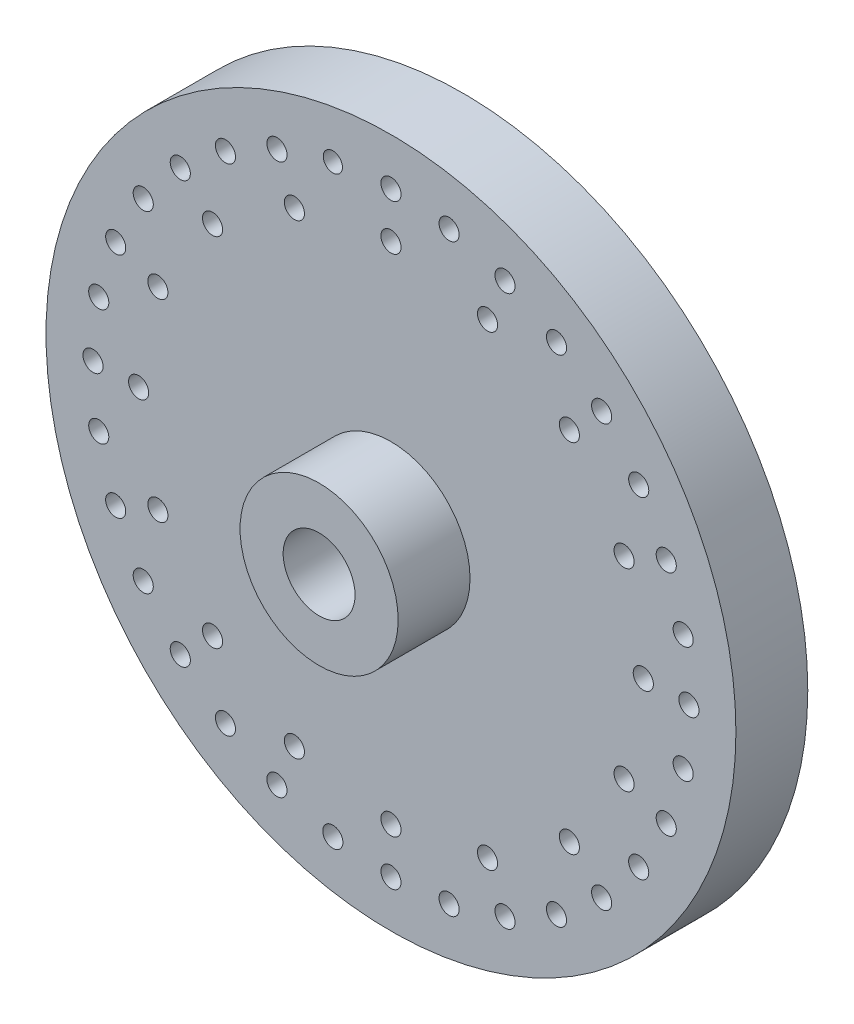
from build123d import *

# Parameters (mm, degrees)
SKETCH1_R          = 24
EXTRUDE1_DEPTH     = 5
SKETCH2_R          = 5.5
EXTRUDE2_DEPTH     = 5
SKETCH3_R          = 2.5
CUT_EXTRUDE1_DEPTH = 11
SKETCH4_R          = 0.7
SKETCH4_R_2        = 0.66767911
CUT_EXTRUDE2_DEPTH = 6


with BuildPart() as part:
    # Sketch1 → Extrude1 (new body)
    with BuildSketch(Plane.XY):
        Circle(SKETCH1_R)
    extrude(amount=EXTRUDE1_DEPTH)

    # Sketch2 → Extrude2 (add)
    with BuildSketch(Plane.XY.offset(5)):
        Circle(SKETCH2_R)
    extrude(amount=EXTRUDE2_DEPTH)

    # Sketch3 → Cut-Extrude1 (cut, through all)
    with BuildSketch(Plane.XY.offset(10)):
        Circle(SKETCH3_R)
    extrude(amount=-CUT_EXTRUDE1_DEPTH, mode=Mode.SUBTRACT)

    # Sketch4 → Cut-Extrude2 (cut, through all)
    with BuildSketch(Plane.XY.offset(5)):
        with Locations((0, 20.73)):
            Circle(SKETCH4_R)
        with Locations((0, -20.73)):
            Circle(SKETCH4_R)
        with Locations((20.73, 0)):
            Circle(SKETCH4_R)
        with Locations((-20.73, 0)):
            Circle(SKETCH4_R)
        with Locations((-14.658, 14.658)):
            Circle(SKETCH4_R)
        with Locations((14.658, 14.658)):
            Circle(SKETCH4_R)
        with Locations((14.658, -14.658)):
            Circle(SKETCH4_R)
        with Locations((-14.658, -14.658)):
            Circle(SKETCH4_R)
        with Locations((19.152, 7.933)):
            Circle(SKETCH4_R)
        with Locations((7.933, 19.152)):
            Circle(SKETCH4_R)
        with Locations((19.152, -7.933)):
            Circle(SKETCH4_R)
        with Locations((7.933, -19.152)):
            Circle(SKETCH4_R)
        with Locations((-7.933, 19.152)):
            Circle(SKETCH4_R)
        with Locations((-19.152, 7.933)):
            Circle(SKETCH4_R)
        with Locations((-19.152, -7.933)):
            Circle(SKETCH4_R)
        with Locations((-7.933, -19.152)):
            Circle(SKETCH4_R)
        with Locations((20.331, 4.044)):
            Circle(SKETCH4_R)
        with Locations((20.331, -4.044)):
            Circle(SKETCH4_R)
        with Locations((4.044, -20.331)):
            Circle(SKETCH4_R)
        with Locations((-4.044, -20.331)):
            Circle(SKETCH4_R)
        with Locations((4.044, 20.331)):
            Circle(SKETCH4_R)
        with Locations((-4.044, 20.331)):
            Circle(SKETCH4_R_2)
        with Locations((-20.331, 4.044)):
            Circle(SKETCH4_R)
        with Locations((-20.331, -4.044)):
            Circle(SKETCH4_R)
        with Locations((17.236, 11.516)):
            Circle(SKETCH4_R)
        with Locations((11.516, 17.236)):
            Circle(SKETCH4_R)
        with Locations((17.236, -11.516)):
            Circle(SKETCH4_R)
        with Locations((11.516, -17.236)):
            Circle(SKETCH4_R)
        with Locations((-11.516, -17.236)):
            Circle(SKETCH4_R)
        with Locations((-17.236, -11.516)):
            Circle(SKETCH4_R)
        with Locations((-17.236, 11.516)):
            Circle(SKETCH4_R)
        with Locations((-11.516, 17.236)):
            Circle(SKETCH4_R)
        with Locations((0, 17.555)):
            Circle(SKETCH4_R)
        with Locations((17.555, 0)):
            Circle(SKETCH4_R)
        with Locations((0, -17.555)):
            Circle(SKETCH4_R)
        with Locations((-17.555, 0)):
            Circle(SKETCH4_R)
        with Locations((-12.413, 12.413)):
            Circle(SKETCH4_R)
        with Locations((12.413, 12.413)):
            Circle(SKETCH4_R)
        with Locations((12.413, -12.413)):
            Circle(SKETCH4_R)
        with Locations((-12.413, -12.413)):
            Circle(SKETCH4_R)
        with Locations((-16.218, 6.718)):
            Circle(SKETCH4_R)
        with Locations((16.218, 6.718)):
            Circle(SKETCH4_R)
        with Locations((16.218, -6.718)):
            Circle(SKETCH4_R)
        with Locations((-16.218, -6.718)):
            Circle(SKETCH4_R)
        with Locations((6.718, 16.218)):
            Circle(SKETCH4_R)
        with Locations((6.718, -16.218)):
            Circle(SKETCH4_R)
        with Locations((-6.718, -16.218)):
            Circle(SKETCH4_R)
        with Locations((-6.718, 16.218)):
            Circle(SKETCH4_R)
    extrude(amount=-CUT_EXTRUDE2_DEPTH, mode=Mode.SUBTRACT)


solid = part.part
